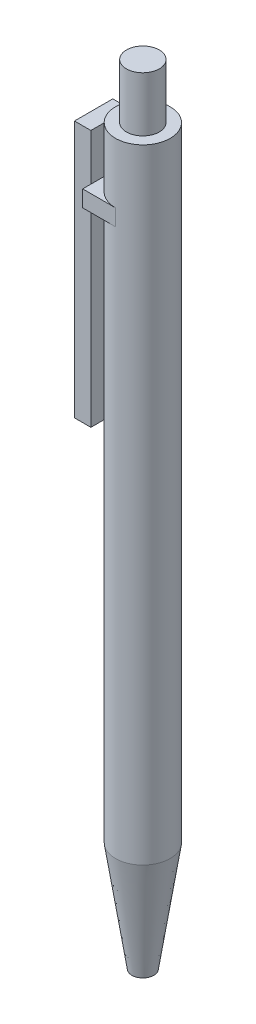
from build123d import *

# Parameters (mm, degrees)
ESBO_O3_R                = 5
RESSALTO_EXTRUS_O1_DEPTH = 100
RESSALTO_EXTRUS_O2_DEPTH = 3
ESBO_O5_W                = 7
ESBO_O5_H                = 47
RESSALTO_EXTRUS_O3_DEPTH = 3
ESBO_O6_R                = 5
RESSALTO_EXTRUS_O4_DEPTH = 11
ESBO_O7_R                = 3
RESSALTO_EXTRUS_O5_DEPTH = 10


with BuildPart() as part:
    # Esboço2 → Revolução1 (revolve)
    with BuildSketch(Plane.XY):
        Polygon((2, 0), (5, 20), (0, 20), (0, 0), align=None)
    revolve(axis=Axis((0, 22.732303323, 0), (0, -1, 0)))

    # Esboço3 → Ressalto-extrusão1 (add)
    with BuildSketch(Plane(origin=(0, 20, 0), x_dir=(1, 0, 0), z_dir=(0, 1, 0))):
        Circle(ESBO_O3_R)
    extrude(amount=RESSALTO_EXTRUS_O1_DEPTH)

    # Esboço4 → Ressalto-extrusão2 (add)
    with BuildSketch(Plane(origin=(0, 120, 0), x_dir=(1, 0, 0), z_dir=(0, 1, 0))):
        with BuildLine():
            Line((-6, 5), (0, 5))
            ThreePointArc((0, 5), (5, 0), (0, -5))
            Line((0, -5), (-6, -5))
            Line((-6, -5), (-6, 5))
        make_face()
    extrude(amount=RESSALTO_EXTRUS_O2_DEPTH)

    # Esboço5 → Ressalto-extrusão3 (add)
    with BuildSketch(Plane.ZY.offset(6)):
        with Locations((0, 108)):
            Rectangle(ESBO_O5_W, ESBO_O5_H)
    extrude(amount=RESSALTO_EXTRUS_O3_DEPTH)

    # Esboço6 → Ressalto-extrusão4 (add)
    with BuildSketch(Plane(origin=(0, 123, 0), x_dir=(1, 0, 0), z_dir=(0, 1, 0))):
        Circle(ESBO_O6_R)
    extrude(amount=RESSALTO_EXTRUS_O4_DEPTH)

    # Esboço7 → Ressalto-extrusão5 (add)
    with BuildSketch(Plane(origin=(0, 134, 0), x_dir=(1, 0, 0), z_dir=(0, 1, 0))):
        Circle(ESBO_O7_R)
    extrude(amount=RESSALTO_EXTRUS_O5_DEPTH)


solid = part.part
